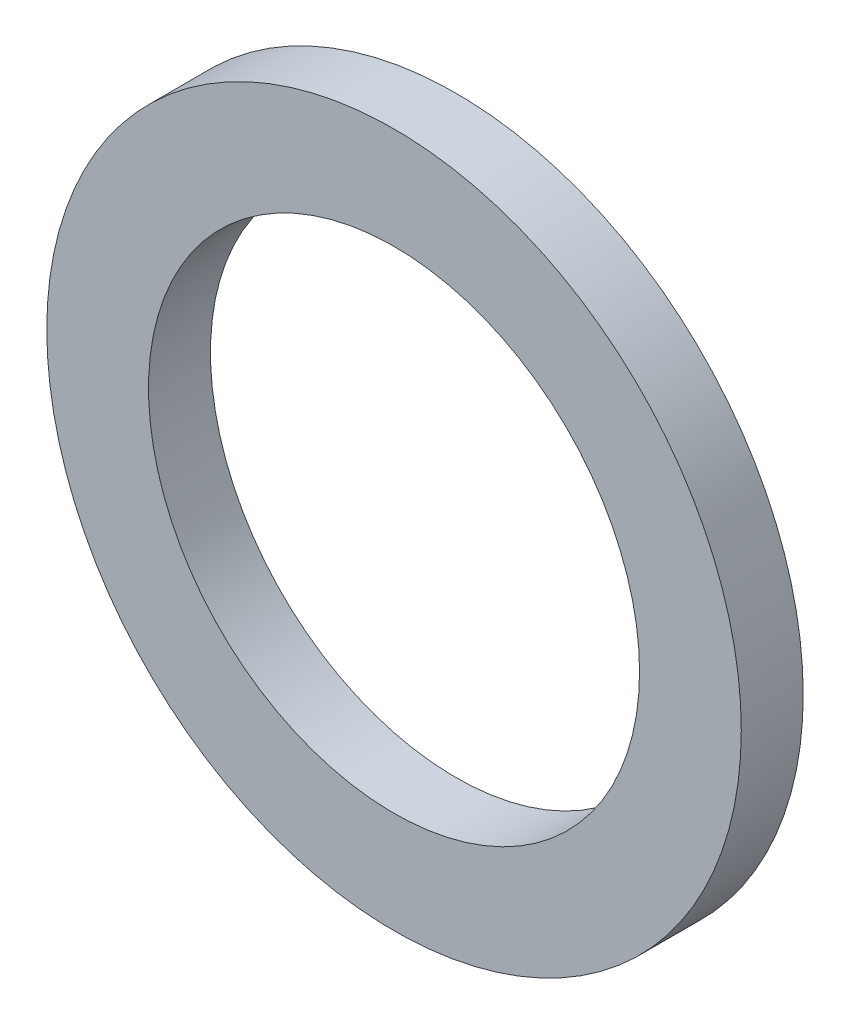
from build123d import *

# Parameters (mm, degrees)
SKETCH1_R           = 7.85
SKETCH1_R_2         = 5.55
BOSS_EXTRUDE1_DEPTH = 1.4


with BuildPart() as part:
    # Sketch1 → Boss-Extrude1 (new body)
    with BuildSketch(Plane.XY):
        Circle(SKETCH1_R)
        Circle(SKETCH1_R_2, mode=Mode.SUBTRACT)
    extrude(amount=BOSS_EXTRUDE1_DEPTH)


solid = part.part
